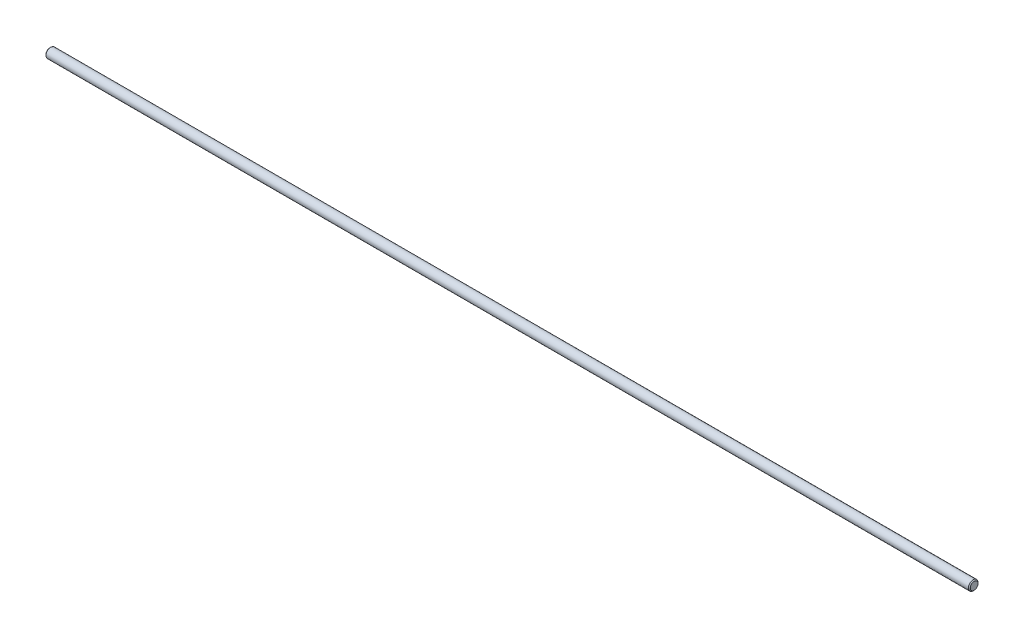
from build123d import *

# Parameters (mm, degrees)
SKETCH2_R           = 3.175
EXTRUDE1_DEPTH      = 304.8
EXTRUDE1_DEPTH_BACK = 304.8
CHAMFER1_SIZE       = 0.635


with BuildPart() as part:
    # Sketch2 → Extrude1 (new body, two sides)
    with BuildSketch(Plane(origin=(0, 0, 0), x_dir=(0, 0, -1), z_dir=(1, 0, 0))) as extrude1_sk:
        Circle(SKETCH2_R)
    extrude(amount=EXTRUDE1_DEPTH)
    extrude(extrude1_sk.sketch, amount=-EXTRUDE1_DEPTH_BACK)

    # Chamfer1
    chamfer1_edges = [part.edges().sort_by_distance(p)[0] for p in [
        (-304.8, 0, 3.175),
        (304.8, 0, 3.175),
    ]]
    chamfer(chamfer1_edges, length=CHAMFER1_SIZE)


solid = part.part
